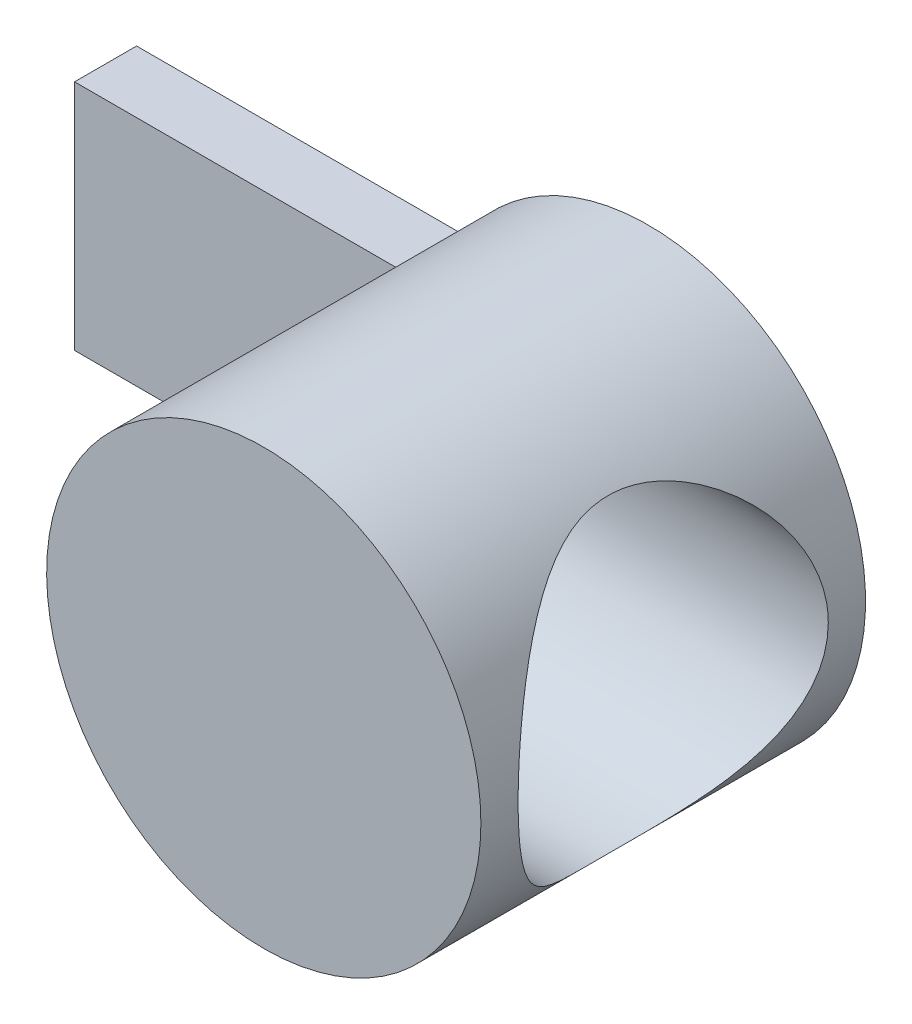
from build123d import *

# Parameters (mm, degrees)
SKETCH_1_R               = 7
EXTRUDE_1_DEPTH          = 12.4
SKETCH_2_W               = 10.589204791
SKETCH_2_H               = 7.5
EXTRUDE_2_DEPTH          = 2
SKETCH_3_R               = 5
CUT_EXTRUDE_1_DEPTH      = 8
CUT_EXTRUDE_1_DEPTH_BACK = 1.5
SKETCH_4_R               = 3.1
CUT_EXTRUDE_2_DEPTH      = 16


with BuildPart() as part:
    # Эскиз1 → Бобышка-Вытянуть1 (new body)
    with BuildSketch(Plane.XY):
        Circle(SKETCH_1_R)
    extrude(amount=EXTRUDE_1_DEPTH)

    # Эскиз2 → Бобышка-Вытянуть2 (add)
    with BuildSketch(Plane.XY):
        with Locations((-11.205397604, 0)):
            Rectangle(SKETCH_2_W, SKETCH_2_H)
    extrude(amount=EXTRUDE_2_DEPTH)

    # Эскиз3 → Вырез-Вытянуть1 (cut, two sides)
    with BuildSketch(Plane(origin=(0, 0, 0), x_dir=(0, 0, -1), z_dir=(1, 0, 0))) as cut_extrude_1_sk:
        with Locations((-6.2, 0)):
            Circle(SKETCH_3_R)
    extrude(amount=CUT_EXTRUDE_1_DEPTH, mode=Mode.SUBTRACT)
    extrude(cut_extrude_1_sk.sketch, amount=-CUT_EXTRUDE_1_DEPTH_BACK, mode=Mode.SUBTRACT)

    # Эскиз4 → Вырез-Вытянуть2 (cut, through all)
    with BuildSketch(Plane(origin=(-1.5, 0, 0), x_dir=(0, 0, -1), z_dir=(1, 0, 0))):
        with Locations((-6.2, 0)):
            Circle(SKETCH_4_R)
    extrude(amount=-CUT_EXTRUDE_2_DEPTH, mode=Mode.SUBTRACT)


solid = part.part
